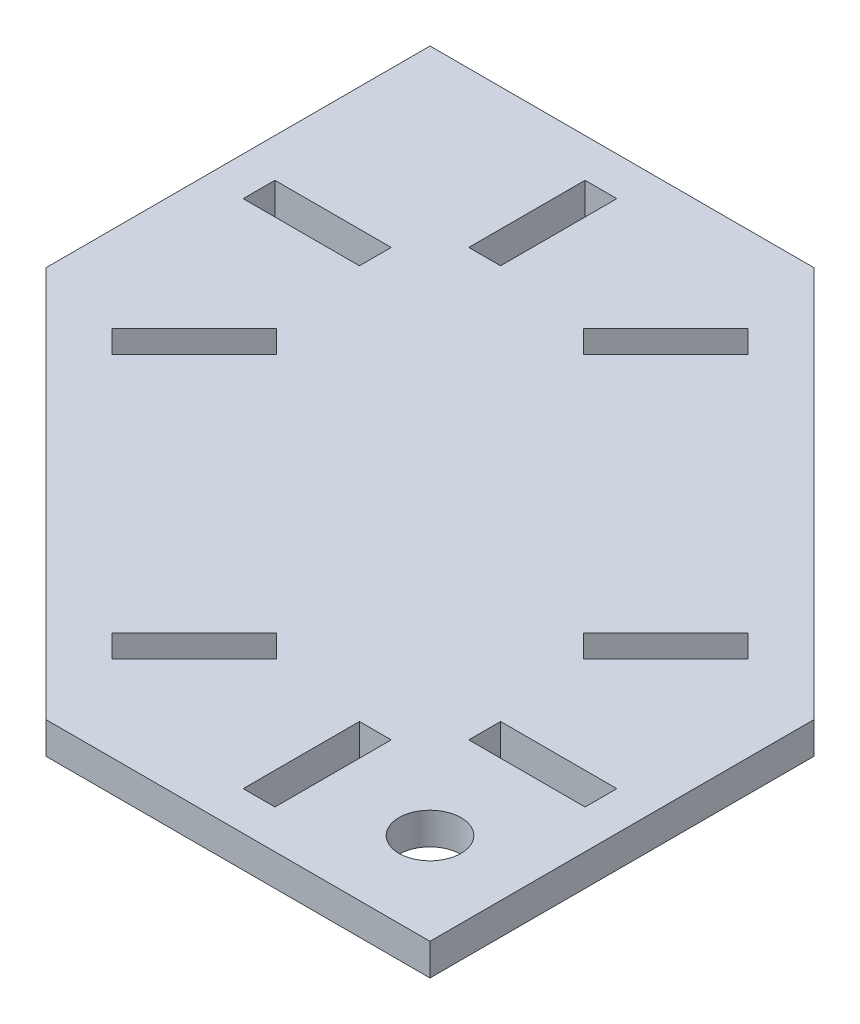
from build123d import *

# Parameters (mm, degrees)
SKETCH1_W           = 100
SKETCH1_H           = 100
SKETCH1_R           = 4
SKETCH1_W_2         = 4.1
SKETCH1_H_2         = 15
SKETCH1_W_3         = 15
SKETCH1_H_3         = 4.1
BOSS_EXTRUDE1_DEPTH = 4.1
CUT_EXTRUDE1_START  = 35
SKETCH2_W           = 141.421356238
SKETCH2_H           = 4.1
CUT_EXTRUDE1_DEPTH  = 35.710678
CUT_EXTRUDE2_REACH  = 107.711
CUT_EXTRUDE2_START  = -35
SKETCH3_W           = 141.421356238
SKETCH3_H           = 4.1
CUT_EXTRUDE3_DEPTH  = 5.1


with BuildPart() as part:
    # Sketch1 → Boss-Extrude1 (new body)
    with BuildSketch(Plane(origin=(0, 0, 0), x_dir=(1, 0, 0), z_dir=(0, 1, 0))):
        Rectangle(SKETCH1_W, SKETCH1_H)
        with Locations((38.183766184, -38.183766184)):
            Circle(SKETCH1_R, mode=Mode.SUBTRACT)
        with Locations((-22.95, 37.5)):
            Rectangle(SKETCH1_W_2, SKETCH1_H_2, mode=Mode.SUBTRACT)
        with Locations((-37.5, 22.95)):
            Rectangle(SKETCH1_W_3, SKETCH1_H_3, mode=Mode.SUBTRACT)
        with Locations((37.5, -22.95)):
            Rectangle(SKETCH1_W_3, SKETCH1_H_3, mode=Mode.SUBTRACT)
        with Locations((22.95, -37.5)):
            Rectangle(SKETCH1_W_2, SKETCH1_H_2, mode=Mode.SUBTRACT)
        with Locations((37.5, 22.95)):
            Rectangle(SKETCH1_W_3, SKETCH1_H_3, mode=Mode.SUBTRACT)
        with Locations((-37.5, -22.95)):
            Rectangle(SKETCH1_W_3, SKETCH1_H_3, mode=Mode.SUBTRACT)
        with Locations((22.95, 37.5)):
            Rectangle(SKETCH1_W_2, SKETCH1_H_2, mode=Mode.SUBTRACT)
        with Locations((-22.95, -37.5)):
            Rectangle(SKETCH1_W_2, SKETCH1_H_2, mode=Mode.SUBTRACT)
    extrude(amount=BOSS_EXTRUDE1_DEPTH)

    # Sketch2 → Cut-Extrude1 (cut)
    with BuildSketch(Plane(origin=(0, 0, 0), x_dir=(0.707106781, 0, 0.707106781), z_dir=(-0.707106781, 0, 0.707106781)).offset(CUT_EXTRUDE1_START)):
        with Locations((0, 2.05)):
            Rectangle(SKETCH2_W, SKETCH2_H)
    extrude(amount=CUT_EXTRUDE1_DEPTH, mode=Mode.SUBTRACT)

    # Sketch3 → Cut-Extrude2 (cut, up to next)
    with BuildSketch(Plane(origin=(0, 0, 0), x_dir=(0.707106781, 0, 0.707106781), z_dir=(-0.707106781, 0, 0.707106781)).offset(CUT_EXTRUDE2_START), mode=Mode.PRIVATE) as cut_extrude2_sk1:
        with Locations((0, 2.05)):
            Rectangle(SKETCH3_W, SKETCH3_H)
    cut_extrude2_tool1 = extrude(cut_extrude2_sk1.sketch, amount=-CUT_EXTRUDE2_REACH, mode=Mode.PRIVATE) & part.part
    add(cut_extrude2_tool1.solids().sort_by_distance((24.748737, 2.05, -24.748737))[0], mode=Mode.SUBTRACT)

    # Sketch4 → Cut-Extrude3 (cut, through all)
    with BuildSketch(Plane(origin=(0, 4.1, 0), x_dir=(1, 0, 0), z_dir=(0, 1, 0))):
        Polygon((-38.961583643, -2.050609665), (-36.062445841, -4.949747468), (-25.455844123, 5.656854249), (-28.354981926, 8.555992052), align=None)
        Polygon((8.555992052, -28.354981926), (-2.050609665, -38.961583643), (-4.949747468, -36.062445841), (5.656854249, -25.455844123), align=None)
        Polygon((38.961583643, 2.050609665), (36.062445841, 4.949747468), (25.455844123, -5.656854249), (28.354981926, -8.555992052), align=None)
        Polygon((-8.555992052, 28.354981926), (2.050609665, 38.961583643), (4.949747468, 36.062445841), (-5.656854249, 25.455844123), align=None)
    extrude(amount=-CUT_EXTRUDE3_DEPTH, mode=Mode.SUBTRACT)


solid = part.part
